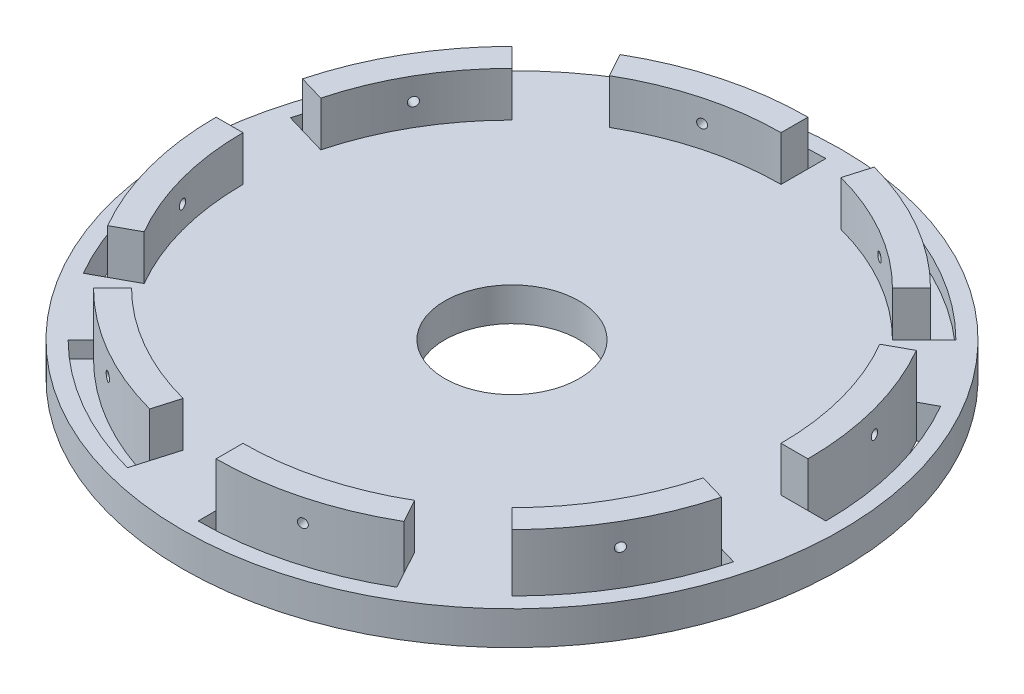
from build123d import *

# Parameters (mm, degrees)
BASE_DEPTH                 = 4.7625
BASE_DEPTH_BACK            = 4.7625
SKETCH1_R                  = 93.345
BOTTOM_SUPPORT_HOLES_DEPTH = 133.352951138
BOTTOM_START               = 12.7
BOTTOM_SUPPORT_GUIDE_DEPTH = 12.7
SKETCH6_R                  = 1.27
BOTTOM_BOLT_HOLE_DEPTH     = 12.7
TOP_SUPPORT_HOLES_DEPTH    = 4.7625
TOP_START                  = 12.7
TOP_SUPPORT_GUIDE_DEPTH    = 12.7
SKETCH12_R                 = 1.27
TOP_BOLT_HOLE_DEPTH        = 12.7
BOTTOM_PATTERN_COUNT       = 4
CIRPATTERN3_COUNT          = 4
SKETCH13_R                 = 19.05
GIMBAL_HOLE_DEPTH          = 25.908


with BuildPart() as part:
    # Sketch1 → Base (new, two sides: drawn at the far end of the back side and taken through both)
    with BuildSketch(Plane(origin=(0, 0, 0), x_dir=(1, 0, 0), z_dir=(0, 1, 0)).offset(-BASE_DEPTH_BACK)):
        Circle(SKETCH1_R)
    extrude(amount=BASE_DEPTH + BASE_DEPTH_BACK)

    # Sketch2 → Bottom support holes (cut, through all)
    with BuildSketch(Plane(origin=(0, 4.7625, 0), x_dir=(1, 0, 0), z_dir=(0, 1, 0))):
        with BuildLine():
            Line((0, 88.9), (0, 83.82))
            ThreePointArc((0, 83.82), (-21.72026739, 80.956916842), (-41.956713931, 72.563258996))
            Line((-41.956713931, 72.563258996), (-44.39288973, 77.022602796))
            ThreePointArc((-44.39288973, 77.022602796), (-22.977169228, 85.879332172), (0, 88.9))
        make_face()
    bottom_support_holes = extrude(amount=-BOTTOM_SUPPORT_HOLES_DEPTH, mode=Mode.SUBTRACT)

    # Sketch3 → Bottom support guide (add)
    with BuildSketch(Plane(origin=(0, 4.7625, 0), x_dir=(1, 0, 0), z_dir=(0, 1, 0)).offset(BOTTOM_START)):
        with BuildLine():
            Line((0, 83.82), (0, 76.2))
            ThreePointArc((0, 76.2), (-19.834896001, 73.573207764), (-38.302281481, 65.8739344))
            Line((-38.302281481, 65.8739344), (-41.956713931, 72.563258996))
            ThreePointArc((-41.956713931, 72.563258996), (-21.72026739, 80.956916842), (0, 83.82))
        make_face()
    bottom_support_guide = extrude(amount=-BOTTOM_SUPPORT_GUIDE_DEPTH)

    # Sketch6 → Bottom bolt hole (cut, symmetric)
    with BuildSketch(Plane(origin=(-20.978356966, 0, -78.191629498), x_dir=(-0.9658424820058785, 0, 0.2591298901183038), z_dir=(-0.2591298901183038, 0, -0.9658424820058785))):
        with Locations((-0.00326739, 11.1125)):
            Circle(SKETCH6_R)
    bottom_bolt_hole = extrude(amount=BOTTOM_BOLT_HOLE_DEPTH, both=True, mode=Mode.SUBTRACT)

    # Sketch8 → Top support holes (cut)
    with BuildSketch(Plane(origin=(-31.122978549, 4.7625, 77.296707326), x_dir=(1, 0, 0), z_dir=(0, 1, 0))):
        with BuildLine():
            Line((-31.738814298, 140.158500173), (-28.14671185, 136.566397725))
            ThreePointArc((-28.14671185, 136.566397725), (-41.480754694, 119.183343848), (-49.854870889, 98.93880289))
            Line((-49.854870889, 98.93880289), (-54.730739557, 100.369398703))
            ThreePointArc((-54.730739557, 100.369398703), (-45.850191767, 121.775253295), (-31.738814298, 140.158500173))
        make_face()
    top_support_holes = extrude(amount=-TOP_SUPPORT_HOLES_DEPTH, mode=Mode.SUBTRACT)

    # Sketch10 → Top support guide (add)
    with BuildSketch(Plane(origin=(-31.122978549, 4.7625, 77.296707326), x_dir=(1, 0, 0), z_dir=(0, 1, 0)).offset(TOP_START)):
        with BuildLine():
            Line((-28.14671185, 136.566397725), (-22.758558177, 131.178244052))
            ThreePointArc((-22.758558177, 131.178244052), (-34.92652504, 115.295431983), (-42.540730139, 96.792810073))
            Line((-42.540730139, 96.792810073), (-49.854870889, 98.93880289))
            ThreePointArc((-49.854870889, 98.93880289), (-41.480754694, 119.183343848), (-28.14671185, 136.566397725))
        make_face()
    top_support_guide = extrude(amount=-TOP_SUPPORT_GUIDE_DEPTH)

    # Sketch12 → Top bolt hole (cut, symmetric)
    with BuildSketch(Plane(origin=(-70.123769919, 0, -40.455892982), x_dir=(-0.4997212660736201, -5.817861610189737e-15, 0.8661862710951832), z_dir=(-0.8661862710951832, 1.404556040332972e-14, -0.4997212660736201))):
        with Locations((-0.00326739, 11.1125)):
            Circle(SKETCH12_R)
    top_bolt_hole = extrude(amount=TOP_BOLT_HOLE_DEPTH, both=True, mode=Mode.SUBTRACT)

    # Bottom pattern: Bottom support holes, Bottom support guide, Bottom bolt hole ×4 about axis
    bottom_pattern_axis = Axis((0, 4.7625, 0), (0, 1, 0))
    add([bottom_support_holes.rotate(bottom_pattern_axis, i * 360 / BOTTOM_PATTERN_COUNT) for i in range(1, BOTTOM_PATTERN_COUNT)], mode=Mode.SUBTRACT)
    add([bottom_support_guide.rotate(bottom_pattern_axis, i * 360 / BOTTOM_PATTERN_COUNT) for i in range(1, BOTTOM_PATTERN_COUNT)])
    add([bottom_bolt_hole.rotate(bottom_pattern_axis, i * 360 / BOTTOM_PATTERN_COUNT) for i in range(1, BOTTOM_PATTERN_COUNT)], mode=Mode.SUBTRACT)

    # CirPattern3: Top support holes, Top support guide, Top bolt hole ×4 about axis
    cirpattern3_axis = Axis((0, 4.7625, 0), (0, 1, 0))
    add([top_support_holes.rotate(cirpattern3_axis, i * 360 / CIRPATTERN3_COUNT) for i in range(1, CIRPATTERN3_COUNT)], mode=Mode.SUBTRACT)
    add([top_support_guide.rotate(cirpattern3_axis, i * 360 / CIRPATTERN3_COUNT) for i in range(1, CIRPATTERN3_COUNT)])
    add([top_bolt_hole.rotate(cirpattern3_axis, i * 360 / CIRPATTERN3_COUNT) for i in range(1, CIRPATTERN3_COUNT)], mode=Mode.SUBTRACT)

    # Sketch13 → Gimbal Hole (cut)
    with BuildSketch(Plane(origin=(0, 4.7625, 0), x_dir=(1, 0, 0), z_dir=(0, 1, 0))):
        Circle(SKETCH13_R)
    extrude(amount=-GIMBAL_HOLE_DEPTH, mode=Mode.SUBTRACT)


solid = part.part
